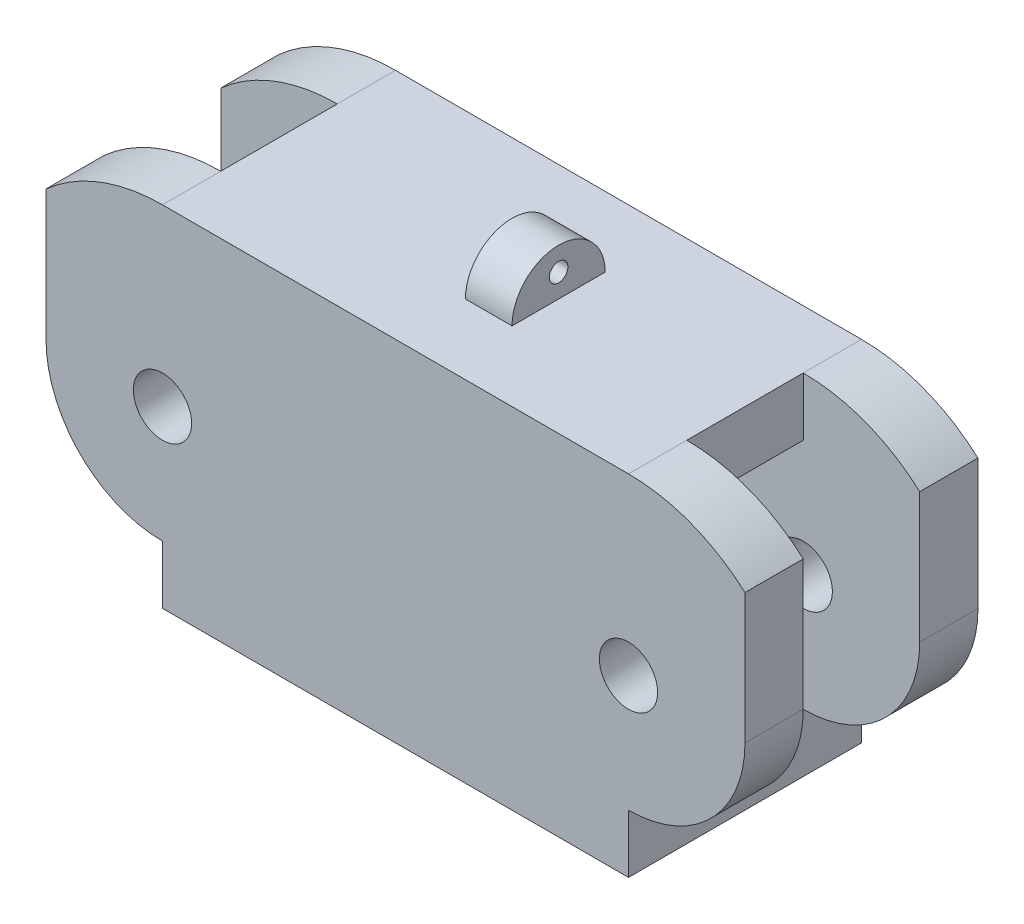
from build123d import *

# Parameters (mm, degrees)
SKETCH1_W           = 44.45
SKETCH1_H           = 19.05
BOSS_EXTRUDE1_DEPTH = 19.05
SKETCH2_R           = 1.5875
CUT_EXTRUDE1_DEPTH  = 19.05
SKETCH9_W           = 2.54
SKETCH9_H           = 5.08
BOSS_EXTRUDE2_DEPTH = 2.54
SKETCH3_R           = 0.508
SKETCH3_W           = 6.35
SKETCH3_H           = 12.7
CUT_EXTRUDE2_DEPTH  = 38.1
SKETCH4_W           = 16.467967332
SKETCH4_H           = 6.35
CUT_EXTRUDE3_DEPTH  = 43.18
CUT_EXTRUDE4_DEPTH  = 19.05
SKETCH7_W           = 15.04890267
SKETCH7_H           = 6.35
CUT_EXTRUDE5_DEPTH  = 3.81


with BuildPart() as part:
    # Sketch1 → Boss-Extrude1 (new body)
    with BuildSketch(Plane(origin=(0, 0, 0), x_dir=(1, 0, 0), z_dir=(0, 1, 0))):
        Rectangle(SKETCH1_W, SKETCH1_H)
    extrude(amount=BOSS_EXTRUDE1_DEPTH)

    # Sketch2 → Cut-Extrude1 (cut)
    with BuildSketch(Plane.XY.offset(9.525)):
        with Locations((-12.7, 9.525)):
            Circle(SKETCH2_R)
        with Locations((12.7, 9.525)):
            Circle(SKETCH2_R)
        with BuildLine():
            ThreePointArc((-12.7, 19.05), (-22.225, 9.525), (-12.7, 0))
            ThreePointArc((-12.7, 0), (-32.914765451, 9.525), (-12.7, 19.05))
        make_face()
        with BuildLine():
            ThreePointArc((12.7, 19.05), (32.914765451, 9.525), (12.7, 0))
            ThreePointArc((12.7, 0), (22.225, 9.525), (12.7, 19.05))
        make_face()
    extrude(amount=-CUT_EXTRUDE1_DEPTH, mode=Mode.SUBTRACT)

    # Sketch9 → Boss-Extrude2 (add)
    with BuildSketch(Plane(origin=(0, 19.05, 0), x_dir=(1, 0, 0), z_dir=(0, 1, 0))):
        with Locations((1.27, 0)):
            Rectangle(SKETCH9_W, SKETCH9_H)
    extrude(amount=BOSS_EXTRUDE2_DEPTH)

    # Sketch3 → Cut-Extrude2 (cut, symmetric)
    with BuildSketch(Plane(origin=(0, 0, 0), x_dir=(0, 0, -1), z_dir=(1, 0, 0))):
        with Locations((0, 20.32)):
            Circle(SKETCH3_R)
        with Locations((0, 9.525)):
            Rectangle(SKETCH3_W, SKETCH3_H)
        with BuildLine():
            ThreePointArc((-2.54, 19.05), (0, 21.59), (2.54, 19.05))
            ThreePointArc((2.54, 19.05), (0, 24.1080653), (-2.54, 19.05))
        make_face()
    extrude(amount=CUT_EXTRUDE2_DEPTH, both=True, mode=Mode.SUBTRACT)

    # Sketch4 → Cut-Extrude3 (cut)
    with BuildSketch(Plane(origin=(0, 19.05, 0), x_dir=(1, 0, 0), z_dir=(0, 1, 0))):
        Polygon((-29.361154188, -9.525), (-12.7, -9.525), (1.5875, -9.525), (28.406626571, -9.525), (28.406626571, -6.35), (1.5875, -6.35), (-12.7, -6.35), (-29.361154188, -6.35), align=None)
        Polygon((-12.7, 6.35), (-31.510324581, 6.35), (-31.510324581, 9.525), (-11.1125, 9.525), (1.5875, 9.525), (30.675017081, 9.525), (30.675017081, 6.35), (1.5875, 6.35), align=None)
        with Locations((20.933983666, 0)):
            Rectangle(SKETCH4_W, SKETCH4_H)
    extrude(amount=-CUT_EXTRUDE3_DEPTH, mode=Mode.SUBTRACT)

    # Sketch6 → Cut-Extrude4 (cut)
    with BuildSketch(Plane.XY.offset(9.525)):
        with BuildLine():
            Line((12.7, 0), (31.980086248, 0))
            Line((31.980086248, 0), (31.980086248, 3.175))
            Line((31.980086248, 3.175), (26.13215645, 13.808491056))
            Line((26.13215645, 13.808491056), (19.05, 19.755698555))
            Line((19.05, 19.755698555), (19.05, 9.525))
            ThreePointArc((19.05, 9.525), (17.190128061, 5.034871939), (12.7, 3.175))
            Line((12.7, 3.175), (12.7, 0))
        make_face()
        with BuildLine():
            Line((-12.7, 0), (-12.7, 3.175))
            ThreePointArc((-12.7, 3.175), (-17.190128061, 5.034871939), (-19.05, 9.525))
            Line((-19.05, 9.525), (-19.05, 20.942771878))
            Line((-19.05, 20.942771878), (-28.921644245, 11.767684684))
            Line((-28.921644245, 11.767684684), (-28.921644245, 0))
            Line((-28.921644245, 0), (-12.7, 0))
        make_face()
    extrude(amount=-CUT_EXTRUDE4_DEPTH, mode=Mode.SUBTRACT)

    # Sketch7 → Cut-Extrude5 (cut)
    with BuildSketch(Plane(origin=(0, 19.05, 0), x_dir=(1, 0, 0), z_dir=(0, 1, 0))):
        with Locations((-20.224451335, 0)):
            Rectangle(SKETCH7_W, SKETCH7_H)
    extrude(amount=-CUT_EXTRUDE5_DEPTH, mode=Mode.SUBTRACT)


solid = part.part
